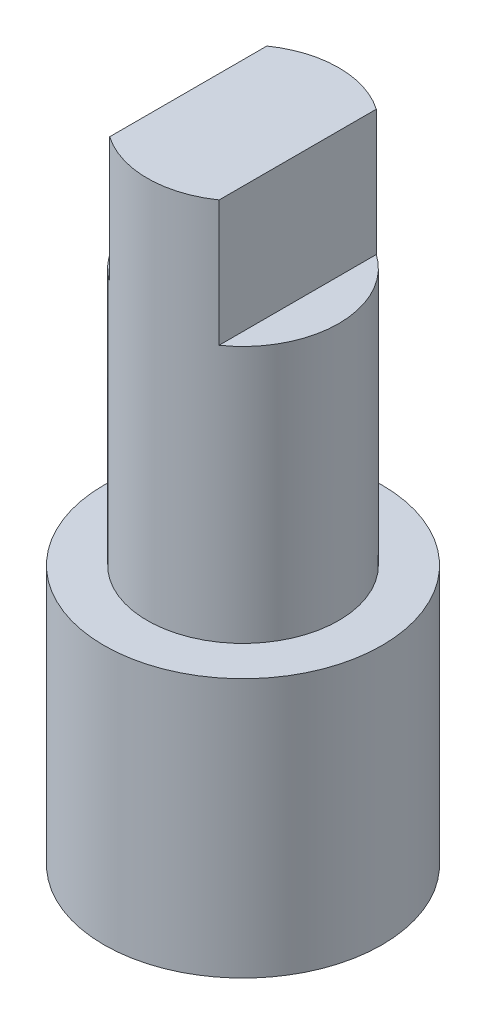
from build123d import *

# Parameters (mm, degrees)
SKETCH1_R           = 1.75
BOSS_EXTRUDE1_DEPTH = 11.738
CUT_EXTRUDE1_DEPTH  = 2.3
SKETCH3_R           = 2.54
BOSS_EXTRUDE2_DEPTH = 4.738


with BuildPart() as part:
    # Sketch1 → Boss-Extrude1 (new body)
    with BuildSketch(Plane(origin=(0, 0, 0), x_dir=(1, 0, 0), z_dir=(0, 1, 0))):
        Circle(SKETCH1_R)
    extrude(amount=BOSS_EXTRUDE1_DEPTH)

    # Sketch2 → Cut-Extrude1 (cut)
    with BuildSketch(Plane(origin=(0, 11.738, 0), x_dir=(1, 0, 0), z_dir=(0, 1, 0))):
        with BuildLine():
            Line((-1, -1.436140662), (-1, 1.436140662))
            ThreePointArc((-1, 1.436140662), (-1.75, 0), (-1, -1.436140662))
        make_face()
        with BuildLine():
            ThreePointArc((1.75, 0), (1.551209206, 0.810092587), (1, 1.436140662))
            Line((1, 1.436140662), (1, -1.436140662))
            ThreePointArc((1, -1.436140662), (1.551209206, -0.810092587), (1.75, 0))
        make_face()
    extrude(amount=-CUT_EXTRUDE1_DEPTH, mode=Mode.SUBTRACT)

    # Sketch3 → Boss-Extrude2 (add)
    with BuildSketch(Plane.XZ):
        Circle(SKETCH3_R)
    extrude(amount=-BOSS_EXTRUDE2_DEPTH)


solid = part.part
